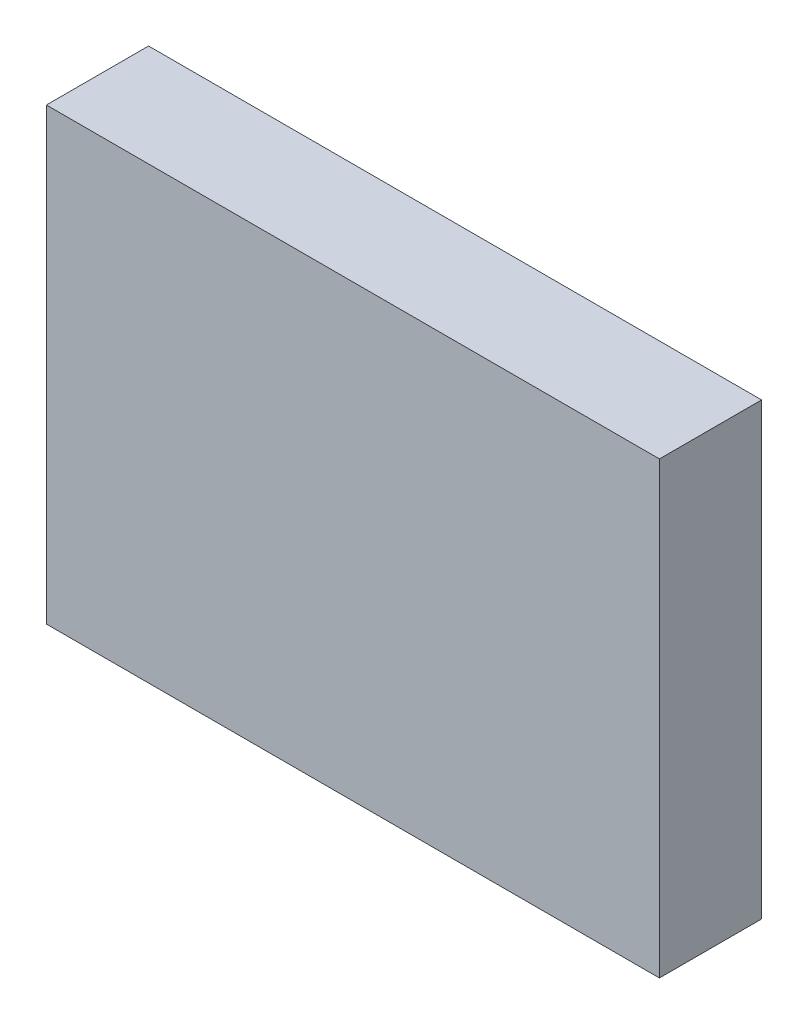
from build123d import *

# Parameters (mm, degrees)
ESQUISSE1_W        = 15
ESQUISSE1_H        = 11
BOSS_EXTRU_1_DEPTH = 2.5


with BuildPart() as part:
    # Esquisse1 → Boss.-Extru.1 (new body)
    with BuildSketch(Plane.XY):
        Rectangle(ESQUISSE1_W, ESQUISSE1_H)
    extrude(amount=BOSS_EXTRU_1_DEPTH)


solid = part.part
